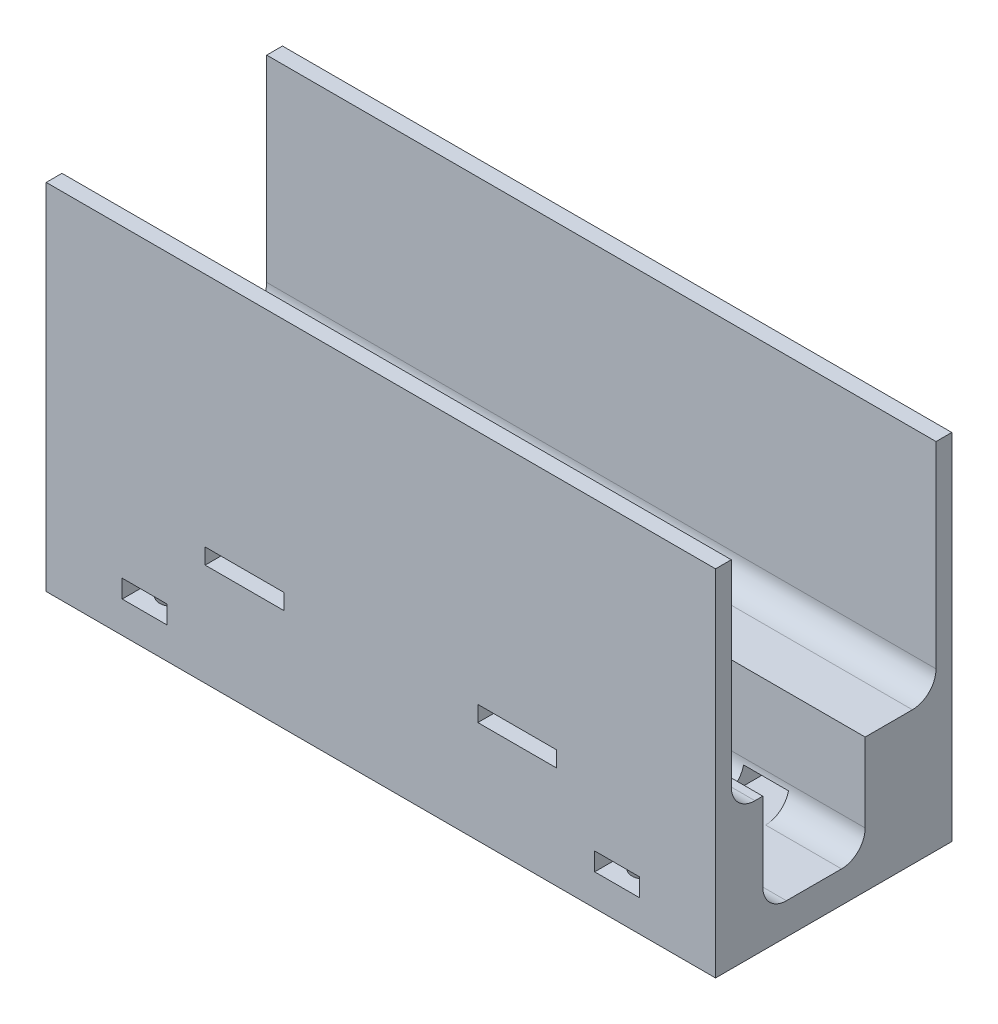
from build123d import *

# Parameters (mm, degrees)
SKETCH_1_W          = 85
SKETCH_1_H          = 30
EXTRUDE_1_DEPTH     = 45
SKETCH_2_W          = 85
SKETCH_2_H          = 26
CUT_EXTRUDE_1_DEPTH = 28
SKETCH_3_W          = 85
SKETCH_3_H          = 13
CUT_EXTRUDE_3_DEPTH = 13
SKETCH_4_W          = 10
SKETCH_4_H          = 2
CUT_EXTRUDE_4_DEPTH = 31
FILLET_1_R          = 3
SKETCH_5_R          = 1.6
CUT_EXTRUDE_5_DEPTH = 8
SKETCH_6_W          = 5.7
SKETCH_6_H          = 2.3
CUT_EXTRUDE_6_DEPTH = 31


with BuildPart() as part:
    # 草图1 → 凸台-拉伸1 (new body)
    with BuildSketch(Plane(origin=(0, 0, 0), x_dir=(1, 0, 0), z_dir=(0, 1, 0))):
        Rectangle(SKETCH_1_W, SKETCH_1_H)
    extrude(amount=EXTRUDE_1_DEPTH)

    # 草图2 → 切除-拉伸1 (cut)
    with BuildSketch(Plane(origin=(0, 45, 0), x_dir=(1, 0, 0), z_dir=(0, 1, 0))):
        Rectangle(SKETCH_2_W, SKETCH_2_H)
    extrude(amount=-CUT_EXTRUDE_1_DEPTH, mode=Mode.SUBTRACT)

    # 草图3 → 切除-拉伸3 (cut)
    with BuildSketch(Plane(origin=(0, 17, 0), x_dir=(1, 0, 0), z_dir=(0, 1, 0))):
        with Locations((0, -2.5)):
            Rectangle(SKETCH_3_W, SKETCH_3_H)
    extrude(amount=-CUT_EXTRUDE_3_DEPTH, mode=Mode.SUBTRACT)

    # 草图4 → 切除-拉伸4 (cut, through all)
    with BuildSketch(Plane.XY.offset(15)):
        with Locations((-17.315675278, 14)):
            Rectangle(SKETCH_4_W, SKETCH_4_H)
        with Locations((17.315675278, 14)):
            Rectangle(SKETCH_4_W, SKETCH_4_H)
    extrude(amount=-CUT_EXTRUDE_4_DEPTH, mode=Mode.SUBTRACT)

    # 圆角1
    fillet_1_edges = [part.edges().sort_by_distance(p)[0] for p in [
        (0, 17, 13),
        (0, 17, -13),
        (0, 4, -4),
        (0, 4, 9),
    ]]
    fillet(fillet_1_edges, radius=FILLET_1_R)

    # 草图5 → 切除-拉伸5 (cut)
    with BuildSketch(Plane.XZ):
        with Locations((-30, 11.5)):
            Circle(SKETCH_5_R)
        with Locations((-30, -11.5)):
            Circle(SKETCH_5_R)
        with Locations((30, -11.5)):
            Circle(SKETCH_5_R)
        with Locations((30, 11.5)):
            Circle(SKETCH_5_R)
    extrude(amount=-CUT_EXTRUDE_5_DEPTH, mode=Mode.SUBTRACT)

    # 草图6 → 切除-拉伸6 (cut, through all)
    with BuildSketch(Plane.XY.offset(15)):
        with Locations((-30, 5.15)):
            Rectangle(SKETCH_6_W, SKETCH_6_H)
        with Locations((30, 5.15)):
            Rectangle(SKETCH_6_W, SKETCH_6_H)
    extrude(amount=-CUT_EXTRUDE_6_DEPTH, mode=Mode.SUBTRACT)


solid = part.part
